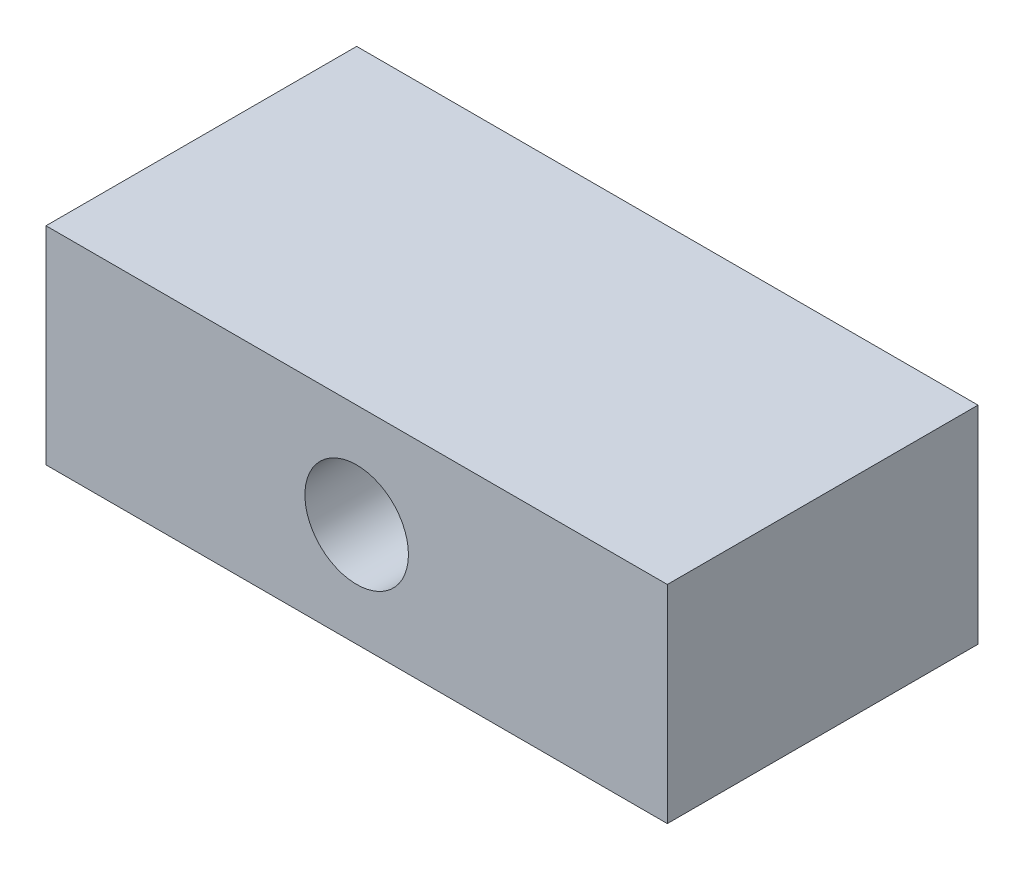
from build123d import *

# Parameters (mm, degrees)
SKETCH1_W           = 300
SKETCH1_H           = 150
BOSS_EXTRUDE1_DEPTH = 50
SKETCH2_R           = 25
CUT_EXTRUDE1_DEPTH  = 151


with BuildPart() as part:
    # Sketch1 → Boss-Extrude1 (new body, symmetric)
    with BuildSketch(Plane(origin=(0, 0, 0), x_dir=(1, 0, 0), z_dir=(0, 1, 0))):
        Rectangle(SKETCH1_W, SKETCH1_H)
    extrude(amount=BOSS_EXTRUDE1_DEPTH, both=True)

    # Sketch2 → Cut-Extrude1 (cut, through all)
    with BuildSketch(Plane.XY.offset(75)):
        Circle(SKETCH2_R)
    extrude(amount=-CUT_EXTRUDE1_DEPTH, mode=Mode.SUBTRACT)


solid = part.part
